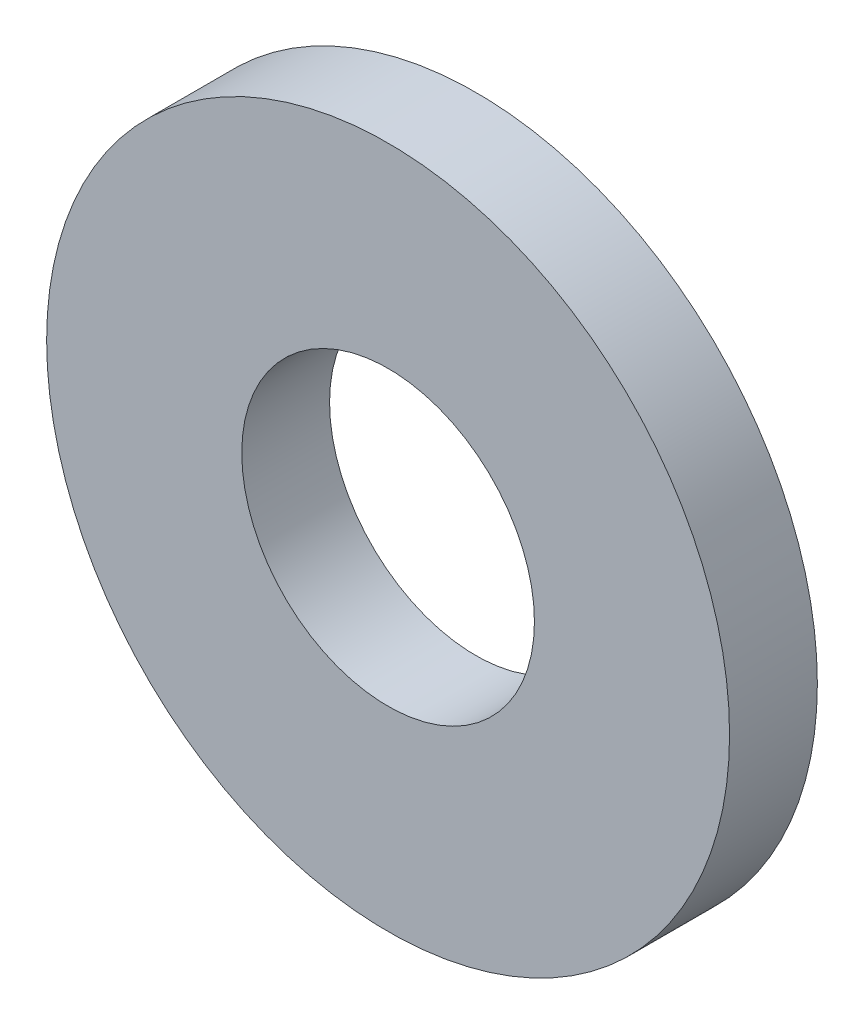
from build123d import *

# Parameters (mm, degrees)
SKETCH1_R           = 3.5
SKETCH1_R_2         = 1.5
BOSS_EXTRUDE1_DEPTH = 0.45


with BuildPart() as part:
    # Sketch1 → Boss-Extrude1 (new body, symmetric)
    with BuildSketch(Plane.XY):
        Circle(SKETCH1_R)
        Circle(SKETCH1_R_2, mode=Mode.SUBTRACT)
    extrude(amount=BOSS_EXTRUDE1_DEPTH, both=True)


solid = part.part
